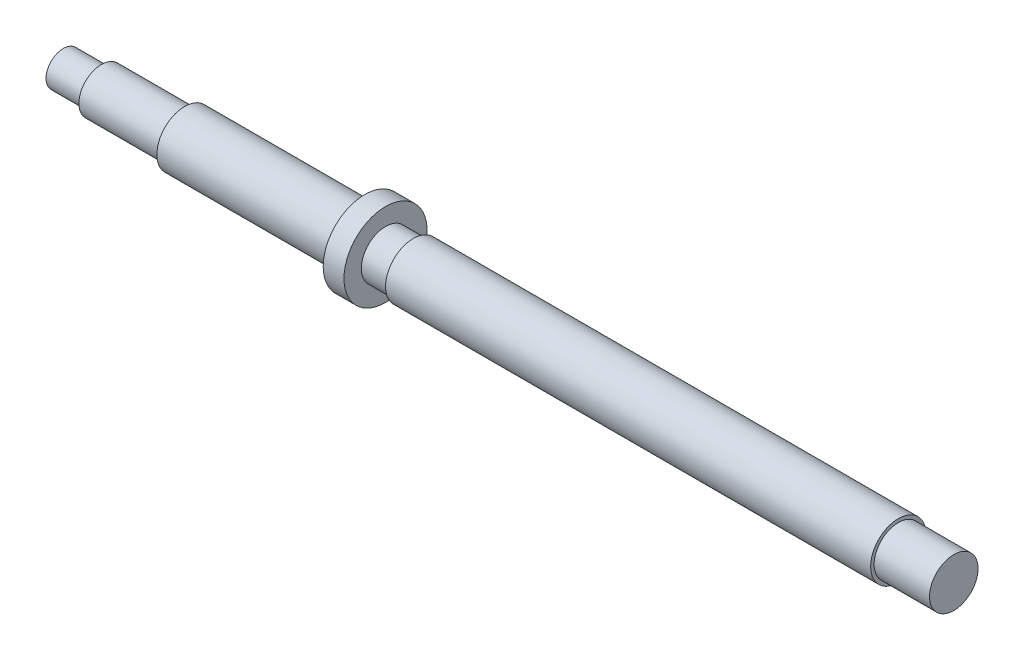
from build123d import *


with BuildPart() as part:
    # Sketch1 → Revolve1 (revolve)
    with BuildSketch(Plane(origin=(0, 0, 0), x_dir=(1, 0, 0), z_dir=(0, 1, 0))):
        Polygon((0, 0), (11, 0), (11, -1.5), (35, -1.5), (35, -3), (87, -3), (87, -7), (93, -7), (93, -2), (101, -2), (101, -3), (241, -3), (241, -2), (257, -2), (257, 5), (0, 5), align=None)
    revolve(axis=Axis((0, 0, -5), (1, 0, 0)))


solid = part.part
